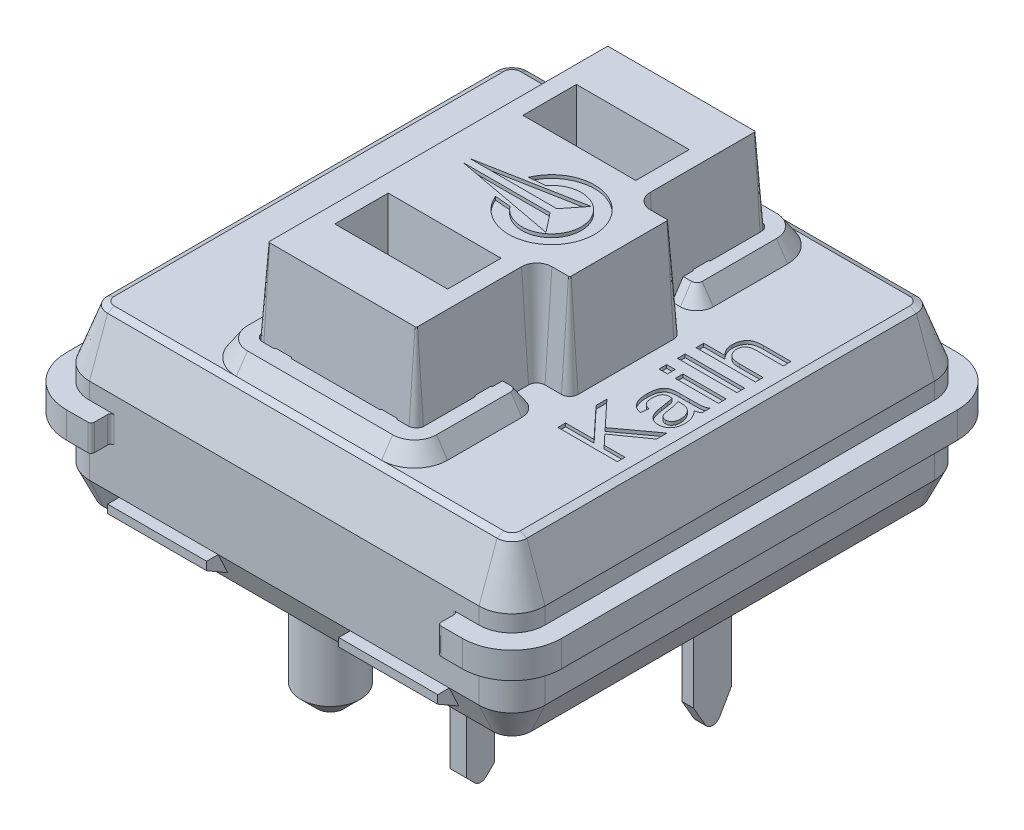
from build123d import *
from OCP.BRepFilletAPI import BRepFilletAPI_MakeChamfer

# Parameters (mm, degrees)
BOSS_EXTRUDE4_DEPTH  = 0.4
BOSS_EXTRUDE5_DEPTH  = 0.5
BOSS_EXTRUDE6_DEPTH  = 1.6
BOSS_EXTRUDE6_TAPER  = 20.000000000000043
CHAMFER1_SIZE        = 0.1
CHAMFER1_SIZE2       = 0.16731571851014881
BOSS_EXTRUDE7_DEPTH  = 0.5
BOSS_EXTRUDE7_TAPER  = 34.000000000000064
CUT_EXTRUDE1_DEPTH   = 11.995908329919814
BOSS_EXTRUDE8_DEPTH  = 0.5
BOSS_EXTRUDE9_DEPTH  = 3
BOSS_EXTRUDE9_DRAFT  = 4.000000000000004
SKETCH13_W           = 1.799999999999999
SKETCH13_H           = 0.23376623376623384
SKETCH13_W_2         = 1.3090909090909086
SKETCH13_H_2         = 0.23376623376623368
SKETCH13_W_3         = 0.25714285714285623
CUT_EXTRUDE2_DEPTH   = 0.1
CUT_EXTRUDE3_DEPTH   = 0.1
BOSS_EXTRUDE10_START = 1.3
BOSS_EXTRUDE10_DEPTH = 1.3
BOSS_EXTRUDE11_DEPTH = 0.9000000000000002
BOSS_EXTRUDE11_TAPER = 25.000000000000018
CUT_EXTRUDE4_DEPTH   = 4
SKETCH19_R           = 1.6
SKETCH19_R_2         = 0.8999999999999999
BOSS_EXTRUDE12_DEPTH = 2.65
CHAMFER2_SIZE        = 0.5
SKETCH20_W           = 0.34999999999999964
SKETCH20_H           = 1.15
SKETCH20_W_2         = 0.5
SKETCH20_H_2         = 0.8499999999999996
BOSS_EXTRUDE13_DEPTH = 3
CUT_EXTRUDE5_REACH   = 18.489
BOSS_EXTRUDE14_START = 2
BOSS_EXTRUDE14_DEPTH = 3
MIRROR2_START        = 2
MIRROR2_COPY_1_DEPTH = 3
CUT_EXTRUDE6_REACH   = 14.137
SKETCH23_W           = 10.5
SKETCH23_H           = 0.599999999999997
FILLET1_R            = 0.1


with BuildPart() as part:
    # Sketch5 → Boss-Extrude4 (new, symmetric)
    with BuildSketch(Plane(origin=(0, 0, 0), x_dir=(1, 0, 0), z_dir=(0, 1, 0))):
        with BuildLine():
            Line((5.999999999999988, -7.4999999999999964), (-5.999999999999988, -7.4999999999999964))
            ThreePointArc((-5.999999999999988, -7.4999999999999964), (-7.06066017177982, -7.060660171779818), (-7.499999999999999, -5.999999999999986))
            Line((-7.499999999999999, -5.999999999999986), (-7.499999999999999, 5.999999999999986))
            ThreePointArc((-7.499999999999999, 5.999999999999986), (-7.06066017177982, 7.060660171779818), (-5.999999999999988, 7.4999999999999964))
            Line((-5.999999999999988, 7.4999999999999964), (5.999999999999988, 7.4999999999999964))
            ThreePointArc((5.999999999999988, 7.4999999999999964), (7.06066017177982, 7.060660171779817), (7.499999999999999, 5.999999999999986))
            Line((7.499999999999999, 5.999999999999986), (7.499999999999999, -5.999999999999986))
            ThreePointArc((7.499999999999999, -5.999999999999986), (7.06066017177982, -7.060660171779817), (5.999999999999988, -7.4999999999999964))
        make_face()
    extrude(amount=BOSS_EXTRUDE4_DEPTH, both=True)

    # Sketch6 → Boss-Extrude5 (add)
    with BuildSketch(Plane(origin=(0, 0.4, 0), x_dir=(1, 0, 0), z_dir=(0, 1, 0))):
        with BuildLine():
            Line((5.899999999999993, -6.900000000000001), (-5.899999999999995, -6.900000000000001))
            ThreePointArc((-5.899999999999995, -6.900000000000001), (-6.607106781186548, -6.607106781186549), (-6.900000000000001, -5.899999999999995))
            Line((-6.900000000000001, -5.899999999999995), (-6.900000000000001, 5.899999999999992))
            ThreePointArc((-6.900000000000001, 5.899999999999992), (-6.607106781186548, 6.6071067811865465), (-5.899999999999995, 6.899999999999999))
            Line((-5.899999999999995, 6.899999999999999), (5.899999999999992, 6.899999999999999))
            ThreePointArc((5.899999999999992, 6.899999999999999), (6.6071067811865465, 6.6071067811865465), (6.899999999999999, 5.899999999999992))
            Line((6.899999999999999, 5.899999999999992), (6.8999999999999995, -5.899999999999995))
            ThreePointArc((6.8999999999999995, -5.899999999999995), (6.607106781186547, -6.607106781186548), (5.899999999999993, -6.900000000000001))
        make_face()
    extrude(amount=BOSS_EXTRUDE5_DEPTH)

    # Sketch7 → Boss-Extrude6 (add)
    with BuildSketch(Plane(origin=(0, 0.9, 0), x_dir=(1, 0, 0), z_dir=(0, 1, 0))):
        with BuildLine():
            Line((-6.900000000000001, 5.899999999999992), (-6.900000000000001, -5.899999999999995))
            ThreePointArc((-6.900000000000001, -5.899999999999995), (-6.607106781186549, -6.607106781186548), (-5.899999999999995, -6.900000000000001))
            Line((-5.899999999999995, -6.900000000000001), (5.899999999999993, -6.900000000000001))
            ThreePointArc((5.899999999999993, -6.900000000000001), (6.607106781186547, -6.607106781186548), (6.8999999999999995, -5.899999999999995))
            Line((6.8999999999999995, -5.899999999999995), (6.899999999999999, 5.899999999999992))
            ThreePointArc((6.899999999999999, 5.899999999999992), (6.6071067811865465, 6.6071067811865465), (5.899999999999992, 6.899999999999999))
            Line((5.899999999999992, 6.899999999999999), (-5.899999999999995, 6.899999999999999))
            ThreePointArc((-5.899999999999995, 6.899999999999999), (-6.607106781186548, 6.6071067811865465), (-6.900000000000001, 5.899999999999992))
        make_face()
    extrude(amount=BOSS_EXTRUDE6_DEPTH, taper=BOSS_EXTRUDE6_TAPER)

    # Chamfer1: one chamfer whose edges measure the first distance from different faces: ONE call of the kernel's chamfer builder (chamfer() names one face for all edges)
    chamfer1_edges_1 = [part.edges().sort_by_distance(p)[0] for p in [
        (-6.195321467907047, 2.5, -6.1953214679070445),
    ]]
    chamfer1_side_1 = [part.faces().sort_by_distance(p)[0] for p in [
        (-6.401214124546798, 1.7000000000000002, -6.4012141245467955),
    ]]
    chamfer1_edges_2 = [part.edges().sort_by_distance(p)[0] for p in [
        (-6.317647625174076, 2.5, 1.38e-15),
    ]]
    chamfer1_side_2 = [part.faces().sort_by_distance(p)[0] for p in [
        (-6.608823812587039, 1.7, 1.04e-15),
    ]]
    chamfer1_edges_3 = [part.edges().sort_by_distance(p)[0] for p in [
        (-6.195321467907047, 2.5, 6.195321467907046),
    ]]
    chamfer1_side_3 = [part.faces().sort_by_distance(p)[0] for p in [
        (-6.401214124546797, 1.7000000000000002, 6.401214124546797),
    ]]
    chamfer1_edges_4 = [part.edges().sort_by_distance(p)[0] for p in [
        (-1.3e-15, 2.5, 6.317647625174076),
    ]]
    chamfer1_side_4 = [part.faces().sort_by_distance(p)[0] for p in [
        (-8.5e-16, 1.7, 6.608823812587039),
    ]]
    chamfer1_edges_5 = [part.edges().sort_by_distance(p)[0] for p in [
        (6.1953214679070445, 2.5, 6.195321467907047),
    ]]
    chamfer1_side_5 = [part.faces().sort_by_distance(p)[0] for p in [
        (6.4012141245467955, 1.7000000000000002, 6.401214124546797),
    ]]
    chamfer1_edges_6 = [part.edges().sort_by_distance(p)[0] for p in [
        (6.317647625174073, 2.5, -3.9e-16),
    ]]
    chamfer1_side_6 = [part.faces().sort_by_distance(p)[0] for p in [
        (6.608823812587037, 1.7000000000000002, 7e-16),
    ]]
    chamfer1_edges_7 = [part.edges().sort_by_distance(p)[0] for p in [
        (6.195321467907045, 2.5, -6.1953214679070445),
    ]]
    chamfer1_side_7 = [part.faces().sort_by_distance(p)[0] for p in [
        (6.4012141245467955, 1.7000000000000002, -6.4012141245467955),
    ]]
    chamfer1_edges_8 = [part.edges().sort_by_distance(p)[0] for p in [
        (-4.1e-16, 2.5, -6.317647625174073),
    ]]
    chamfer1_side_8 = [part.faces().sort_by_distance(p)[0] for p in [
        (-8.5e-16, 1.7, -6.608823812587036),
    ]]
    chamfer1 = BRepFilletAPI_MakeChamfer(part.part.solid().wrapped)
    for e in chamfer1_edges_1:
        chamfer1.Add(CHAMFER1_SIZE, CHAMFER1_SIZE2, e.wrapped, chamfer1_side_1[0].wrapped)  # the first distance lies on this face
    for e in chamfer1_edges_2:
        chamfer1.Add(CHAMFER1_SIZE, CHAMFER1_SIZE2, e.wrapped, chamfer1_side_2[0].wrapped)  # the first distance lies on this face
    for e in chamfer1_edges_3:
        chamfer1.Add(CHAMFER1_SIZE, CHAMFER1_SIZE2, e.wrapped, chamfer1_side_3[0].wrapped)  # the first distance lies on this face
    for e in chamfer1_edges_4:
        chamfer1.Add(CHAMFER1_SIZE, CHAMFER1_SIZE2, e.wrapped, chamfer1_side_4[0].wrapped)  # the first distance lies on this face
    for e in chamfer1_edges_5:
        chamfer1.Add(CHAMFER1_SIZE, CHAMFER1_SIZE2, e.wrapped, chamfer1_side_5[0].wrapped)  # the first distance lies on this face
    for e in chamfer1_edges_6:
        chamfer1.Add(CHAMFER1_SIZE, CHAMFER1_SIZE2, e.wrapped, chamfer1_side_6[0].wrapped)  # the first distance lies on this face
    for e in chamfer1_edges_7:
        chamfer1.Add(CHAMFER1_SIZE, CHAMFER1_SIZE2, e.wrapped, chamfer1_side_7[0].wrapped)  # the first distance lies on this face
    for e in chamfer1_edges_8:
        chamfer1.Add(CHAMFER1_SIZE, CHAMFER1_SIZE2, e.wrapped, chamfer1_side_8[0].wrapped)  # the first distance lies on this face
    add(Compound.cast(chamfer1.Shape()), mode=Mode.REPLACE)

    # Sketch8 → Boss-Extrude7 (add)
    with BuildSketch(Plane(origin=(0, 2.5, 0), x_dir=(1, 0, 0), z_dir=(0, 1, 0))):
        with BuildLine():
            ThreePointArc((2.1999999999999926, -6.150331906663926), (2.907106781186547, -5.857438687850474), (3.1999999999999997, -5.150331906663919))
            Line((3.1999999999999997, -5.150331906663919), (3.1999999999999997, -2.9003319066639257))
            ThreePointArc((3.1999999999999997, -2.9003319066639257), (3.0535533905932737, -2.5467785160706518), (2.6999999999999997, -2.4003319066639257))
            Line((2.6999999999999997, -2.4003319066639257), (2.3000000000000003, -2.4003319066639257))
            Line((2.3000000000000003, -2.4003319066639257), (2.3, 2.4003319066639257))
            Line((2.3, 2.4003319066639257), (2.699999999999996, 2.4003319066639257))
            ThreePointArc((2.699999999999996, 2.4003319066639257), (3.0535533905932737, 2.5467785160706518), (3.1999999999999997, 2.9003319066639293))
            Line((3.1999999999999997, 2.9003319066639293), (3.1999999999999997, 5.150331906663919))
            ThreePointArc((3.1999999999999997, 5.150331906663919), (2.907106781186547, 5.857438687850474), (2.1999999999999926, 6.150331906663926))
            Line((2.1999999999999926, 6.150331906663926), (-2.1999999999999935, 6.150331906663926))
            ThreePointArc((-2.1999999999999935, 6.150331906663926), (-2.907106781186548, 5.857438687850474), (-3.2000000000000006, 5.150331906663919))
            Line((-3.2000000000000006, 5.150331906663919), (-3.2000000000000006, -5.150331906663919))
            ThreePointArc((-3.2000000000000006, -5.150331906663919), (-2.907106781186548, -5.857438687850474), (-2.1999999999999935, -6.150331906663926))
            Line((-2.1999999999999935, -6.150331906663926), (2.1999999999999926, -6.150331906663926))
        make_face()
    extrude(amount=BOSS_EXTRUDE7_DEPTH, taper=BOSS_EXTRUDE7_TAPER)

    # Sketch9 → Cut-Extrude1 (cut, through all)
    with BuildSketch(Plane(origin=(0, 2.5, 0), x_dir=(1, 0, 0), z_dir=(0, 1, 0))):
        with BuildLine():
            Line((-2.1999999999999997, -5.35), (2.2, -5.35))
            ThreePointArc((2.2, -5.35), (2.376776695296637, -5.276776695296636), (2.4500000000000006, -5.1))
            Line((2.4500000000000006, -5.1), (2.4500000000000006, 5.1))
            ThreePointArc((2.4500000000000006, 5.1), (2.376776695296637, 5.276776695296636), (2.2, 5.35))
            Line((2.2, 5.35), (-2.1999999999999997, 5.35))
            ThreePointArc((-2.1999999999999997, 5.35), (-2.3767766952966367, 5.276776695296636), (-2.4499999999999997, 5.1))
            Line((-2.4499999999999997, 5.1), (-2.4499999999999997, -5.1))
            ThreePointArc((-2.4499999999999997, -5.1), (-2.3767766952966367, -5.276776695296636), (-2.1999999999999997, -5.35))
        make_face()
    extrude(amount=CUT_EXTRUDE1_DEPTH, mode=Mode.SUBTRACT)

    # Sketch11 → Boss-Extrude8 (add)
    with BuildSketch(Plane(origin=(0, 2.5, 0), x_dir=(1, 0, 0), z_dir=(0, 1, 0))):
        with BuildLine():
            Line((-1.8598076211353325, 5.35), (-1.3401923788646686, 5.3500000000000005))
            ThreePointArc((-1.3401923788646686, 5.3500000000000005), (-1.6000000000000003, 5.199999999999999), (-1.8598076211353325, 5.35))
        make_face()
        with BuildLine():
            Line((1.3401923788646686, 5.3500000000000005), (1.8598076211353325, 5.35))
            ThreePointArc((1.8598076211353325, 5.35), (1.6000000000000003, 5.199999999999999), (1.3401923788646686, 5.3500000000000005))
        make_face()
        with BuildLine():
            Line((2.4500000000000006, 3.5598076211353322), (2.4500000000000006, 3.040192378864668))
            ThreePointArc((2.4500000000000006, 3.040192378864668), (2.2999999999999994, 3.3), (2.4500000000000006, 3.5598076211353322))
        make_face()
        with BuildLine():
            Line((2.4500000000000006, -3.0401923788646683), (2.4500000000000006, -3.5598076211353313))
            ThreePointArc((2.4500000000000006, -3.5598076211353313), (2.3000000000000007, -3.3), (2.4500000000000006, -3.0401923788646683))
        make_face()
        with BuildLine():
            Line((1.859807621135331, -5.35), (1.3401923788646677, -5.35))
            ThreePointArc((1.3401923788646677, -5.35), (1.6, -5.199999999999998), (1.859807621135331, -5.35))
        make_face()
        with BuildLine():
            Line((-1.3401923788646677, -5.35), (-1.859807621135331, -5.35))
            ThreePointArc((-1.859807621135331, -5.35), (-1.5999999999999992, -5.199999999999999), (-1.3401923788646677, -5.35))
        make_face()
        with BuildLine():
            Line((-2.4499999999999997, -3.5598076211353313), (-2.4499999999999993, -3.0401923788646683))
            ThreePointArc((-2.4499999999999993, -3.0401923788646683), (-2.2999999999999994, -3.3000000000000003), (-2.4499999999999997, -3.5598076211353313))
        make_face()
        with BuildLine():
            Line((-2.449999999999999, 3.0401923788646683), (-2.449999999999999, 3.5598076211353313))
            ThreePointArc((-2.449999999999999, 3.5598076211353313), (-2.299999999999999, 3.3), (-2.449999999999999, 3.0401923788646683))
        make_face()
    extrude(amount=BOSS_EXTRUDE8_DEPTH)


with BuildPart() as boss_extrude9_tool:
    # Sketch12 → Boss-Extrude9 (with draft: the straight prism first)
    with BuildSketch(Plane(origin=(0, 2.5, 0), x_dir=(1, 0, 0), z_dir=(0, 1, 0))):
        with BuildLine():
            ThreePointArc((2.6999999999999993, 1.6999999999999997), (2.5232233047033628, 1.7732233047033628), (2.4499999999999993, 1.9499999999999995))
            Line((2.4499999999999993, 1.9499999999999995), (2.4499999999999997, 5.099999999999998))
            ThreePointArc((2.4499999999999997, 5.099999999999998), (2.3767766952966367, 5.276776695296637), (2.199999999999998, 5.35))
            Line((2.199999999999998, 5.35), (-2.199999999999998, 5.35))
            ThreePointArc((-2.199999999999998, 5.35), (-2.3767766952966367, 5.276776695296637), (-2.4499999999999997, 5.099999999999998))
            Line((-2.4499999999999997, 5.099999999999998), (-2.4499999999999997, -5.099999999999998))
            ThreePointArc((-2.4499999999999997, -5.099999999999998), (-2.3767766952966367, -5.276776695296637), (-2.199999999999998, -5.35))
            Line((-2.199999999999998, -5.35), (2.199999999999998, -5.35))
            ThreePointArc((2.199999999999998, -5.35), (2.3767766952966367, -5.276776695296636), (2.4499999999999997, -5.099999999999998))
            Line((2.4499999999999997, -5.099999999999998), (2.449999999999999, -1.9500000000000004))
            ThreePointArc((2.449999999999999, -1.9500000000000004), (2.5232233047033623, -1.7732233047033634), (2.6999999999999993, -1.7000000000000004))
            Line((2.6999999999999993, -1.7000000000000004), (3.1999999999999975, -1.7000000000000006))
            ThreePointArc((3.1999999999999975, -1.7000000000000006), (3.3767766952966363, -1.6267766952966372), (3.4499999999999993, -1.4499999999999986))
            Line((3.4499999999999993, -1.4499999999999986), (3.4499999999999993, 1.449999999999998))
            ThreePointArc((3.4499999999999993, 1.449999999999998), (3.3767766952966363, 1.6267766952966367), (3.1999999999999975, 1.6999999999999997))
            Line((3.1999999999999975, 1.6999999999999997), (2.6999999999999993, 1.6999999999999997))
        make_face()
        Polygon((-1.5000000000000004, -2.2500000000000013), (1.4999999999999996, -2.2500000000000013), (1.5, -3.4500000000000006), (-1.5, -3.4500000000000006), align=None, mode=Mode.SUBTRACT)
        Polygon((1.4999999999999996, 2.2500000000000013), (1.5, 3.4500000000000006), (-1.5, 3.4500000000000006), (-1.5000000000000004, 2.2500000000000013), align=None, mode=Mode.SUBTRACT)
    extrude(amount=BOSS_EXTRUDE9_DEPTH)
    # Boss-Extrude9: the draft: its side faces are tilted about the plane it starts from
    boss_extrude9_sides = [boss_extrude9_tool.faces().sort_by_distance(p)[0] for p in [
        (2.95, 4, -1.7),
        (2.523223305, 4, -1.773223305),
        (2.45, 4, -3.525),
        (2.376776695, 4, -5.276776695),
        (0, 4, -5.35),
        (-2.376776695, 4, -5.276776695),
        (-2.45, 4, 0),
        (-2.376776695, 4, 5.276776695),
        (0, 4, 5.35),
        (2.376776695, 4, 5.276776695),
        (2.45, 4, 3.525),
        (2.523223305, 4, 1.773223305),
        (2.95, 4, 1.7),
        (3.376776695, 4, 1.626776695),
        (3.45, 4, 0),
        (3.376776695, 4, -1.626776695),
        (0, 4, 2.25),
        (1.5, 4, 2.85),
        (0, 4, 3.45),
        (-1.5, 4, 2.85),
        (0, 4, -2.25),
        (-1.5, 4, -2.85),
        (0, 4, -3.45),
        (1.5, 4, -2.85),
    ]]
    draft(boss_extrude9_sides, Plane(origin=(0, 2.5, 0), x_dir=(1, 0, 0), z_dir=(0, 1, 0)), BOSS_EXTRUDE9_DRAFT)


with BuildPart() as part_1:
    add(part.part)

    # Boss-Extrude9: add boss_extrude9_tool
    add(boss_extrude9_tool.part)

    # Sketch13 → Cut-Extrude2 (cut)
    # profile 1 of 6: a face of its own
    with BuildSketch(Plane(origin=(0, 2.5, 0), x_dir=(1, 0, 0), z_dir=(0, 1, 0))):
        with BuildLine():
            Line((5.808966831260708, 2.641558441558442), (5.808966831260708, 2.407792207792208))
            Line((5.808966831260708, 2.407792207792208), (4.983845078013955, 2.407792207792208))
            add(Edge.make_bspline(
                [(4.983845078013955, 2.407792207792208), (4.970936937987347, 2.407542406260028), (4.945817291259644, 2.4070562846168273), (4.909388829537622, 2.404446327773024), (4.875533983787305, 2.3986845529071656), (4.844041788617271, 2.3916782041743367), (4.815157057405047, 2.3820295974230006), (4.788467982544043, 2.370938235014907), (4.76477812513214, 2.356842463642668), (4.74322837391324, 2.3411870649661166), (4.724636948675216, 2.322986558780508), (4.707844497346048, 2.3033641068930986), (4.694403121572682, 2.2809814749147597), (4.682944049961972, 2.256818630216123), (4.6742465252240155, 2.230417316179967), (4.668184159240792, 2.2019983442445166), (4.66389616835546, 2.1717202021884994), (4.6636423768311674, 2.150786980540251), (4.6635122858061635, 2.1400568181818187)],
                knots=[0, 0, 0, 0, 1.2972783551700766, 2.5245445061948706, 3.6648949627077094, 4.745058113257756, 5.762506365238955, 6.7214970436470525, 7.642596806820658, 8.525874585350033, 9.39109206720355, 10.251017649372987, 11.113376332231878, 12.005421350727158, 12.933884526935351, 13.898554589722258, 14.922819868887679, 16, 16, 16, 16], degree=3))
            add(Edge.make_bspline(
                [(4.6635122858061635, 2.1400568181818187), (4.663785205943969, 2.1292047975292503), (4.664327167446585, 2.107654986414011), (4.66891947185136, 2.0757509701628627), (4.6760240121807595, 2.0445829921752665), (4.686851369518582, 2.014620956025939), (4.700167829324783, 1.9854327210485339), (4.716078390118673, 1.9568415750558832), (4.73570868933388, 1.9296426160727786), (4.7575320886071655, 1.9029132005118794), (4.783330672401592, 1.8782273309201394), (4.814429220574406, 1.8572274976130505), (4.849948580547092, 1.8394512413448831), (4.89005592438308, 1.8249217409321132), (4.934595652434697, 1.8136176473029308), (4.983754863262196, 1.8059125229971111), (5.037541460961735, 1.800531571486795), (5.075023484650014, 1.800181881897381), (5.094518779312656, 1.8000000000000005)],
                knots=[0, 0, 0, 0, 0.8362054097120233, 1.6605265700973175, 2.4801317730402395, 3.2965059310675793, 4.1113678837462215, 4.951934169313966, 5.813922886019306, 6.693615501295894, 7.6099018852787, 8.554965245663075, 9.57498769822485, 10.664785272825679, 11.83718286940016, 13.111757415166943, 14.497756131931636, 16, 16, 16, 16], degree=3))
            Line((5.094518779312656, 1.8000000000000005), (5.808966831260708, 1.8000000000000005))
            Line((5.808966831260708, 1.8000000000000005), (5.808966831260708, 1.5662337662337664))
            Line((5.808966831260708, 1.5662337662337664), (4.008966831260709, 1.5662337662337664))
            Line((4.008966831260709, 1.5662337662337664), (4.008966831260709, 1.8000000000000005))
            Line((4.008966831260709, 1.8000000000000005), (4.654746052039929, 1.8000000000000005))
            add(Edge.make_bspline(
                [(4.654746052039929, 1.8000000000000005), (4.640587268225019, 1.8132416381214425), (4.612790149898402, 1.8392381775496645), (4.576436737364106, 1.8823687896270296), (4.545512997028346, 1.9278700105851003), (4.520153010498332, 1.9758505241977433), (4.500661093710448, 2.026392369279579), (4.486816633622833, 2.079314401328632), (4.478177777445173, 2.1347826772544454), (4.477065304085907, 2.1726549891213955), (4.476499298793176, 2.1919237012987014)],
                knots=[0, 0, 0, 0, 1.0459544956214468, 2.0534617421327868, 3.0380182977429215, 4.011318372678219, 4.9769517403428445, 5.955962446214011, 6.9600325577727205, 8, 8, 8, 8], degree=3))
            add(Edge.make_bspline(
                [(4.476499298793176, 2.1919237012987014), (4.477151582793741, 2.21277888482019), (4.478447675797427, 2.254218284574451), (4.488265102185742, 2.3157097148811725), (4.504316498091638, 2.3757223907282032), (4.523072482923445, 2.424142919941128), (4.5413475287910305, 2.460944025525365), (4.556678390313753, 2.486720067646266), (4.573903343982798, 2.510222970711106), (4.592950461451007, 2.5314273616548295), (4.613634983780957, 2.550582276277968), (4.635796332997107, 2.567919296762635), (4.660269486175782, 2.582453577853053), (4.686358421444562, 2.595400662956551), (4.714781427402648, 2.6063064439066825), (4.745540233069591, 2.6157833065900173), (4.778855645113474, 2.623760719216385), (4.814825745795724, 2.630327347062428), (4.853357065642652, 2.6353283002399457), (4.894542377636706, 2.6389704691017455), (4.938285293293962, 2.641164747420887), (4.968379824838619, 2.64142480221953), (4.983845078013955, 2.641558441558442)],
                knots=[0, 0, 0, 0, 1.5968089331520274, 3.172870842583649, 4.756281426330583, 6.34771723513016, 7.140081275106954, 7.901324872717275, 8.641779931057476, 9.368185131844692, 10.08081263976222, 10.798910289841917, 11.5185804625579, 12.256741901371203, 13.027352034049343, 13.847329809568349, 14.720365742585669, 15.649518335311587, 16.64656909042814, 17.695141442598235, 18.815558199646286, 20, 20, 20, 20], degree=3))
            Line((4.983845078013955, 2.641558441558442), (5.808966831260708, 2.641558441558442))
        make_face()
    # profile 2 of 6: a face of its own
    with BuildSketch(Plane(origin=(0, 2.5, 0), x_dir=(1, 0, 0), z_dir=(0, 1, 0))):
        with Locations((4.908966831260709, 1.1220779220779225)):
            Rectangle(SKETCH13_W, SKETCH13_H)
    # profile 3 of 6: a face of its own
    with BuildSketch(Plane(origin=(0, 2.5, 0), x_dir=(1, 0, 0), z_dir=(0, 1, 0))):
        with Locations((5.154421376715254, 0.5610389610389616)):
            Rectangle(SKETCH13_W_2, SKETCH13_H_2)
    # profile 4 of 6: a face of its own
    with BuildSketch(Plane(origin=(0, 2.5, 0), x_dir=(1, 0, 0), z_dir=(0, 1, 0))):
        with Locations((4.137538259832137, 0.5610389610389616)):
            Rectangle(SKETCH13_W_3, SKETCH13_H_2)
    # profile 5 of 6: a face of its own
    with BuildSketch(Plane(origin=(0, 2.5, 0), x_dir=(1, 0, 0), z_dir=(0, 1, 0))):
        with BuildLine():
            Line((5.808966831260708, 0.18701298701298769), (5.808966831260708, -0.04675324675324595))
            add(Edge.make_bspline(
                [(5.808966831260708, -0.04675324675324595), (5.7976142124163745, -0.05478679368631185), (5.7743238351672606, -0.07126795466644732), (5.733813191132734, -0.08980997433740275), (5.689119615174492, -0.10624044539384754), (5.656887568182907, -0.11325507851090857), (5.640216831260709, -0.11688311688311617)],
                knots=[0, 0, 0, 0, 0.903907977573099, 1.8544054094329567, 2.8902770286238817, 4, 4, 4, 4], degree=3))
            add(Edge.make_bspline(
                [(5.640216831260709, -0.11688311688311617), (5.655516269991555, -0.13501758155964783), (5.685611532777377, -0.17068957512239877), (5.724423214156069, -0.22753996575106764), (5.758209315632795, -0.2850162411995688), (5.785193746113217, -0.3439309765148028), (5.806296030921507, -0.40396525614362766), (5.821118572850905, -0.4650232117771859), (5.830806032465317, -0.5272477785338032), (5.83182865628761, -0.5691604908149904), (5.832343454637331, -0.5902597402597396)],
                knots=[0, 0, 0, 0, 1.0892239949737048, 2.142593786481002, 3.1574900276556006, 4.148481358184637, 5.114232063249363, 6.075958248606488, 7.031419475255834, 8, 8, 8, 8], degree=3))
            add(Edge.make_bspline(
                [(5.832343454637331, -0.5902597402597396), (5.832153360297348, -0.6068352336235396), (5.831783364459901, -0.6390974437912494), (5.826299867785243, -0.6860584678131948), (5.818566199820707, -0.7303404833298883), (5.807164390100491, -0.7719074962510519), (5.792565368740574, -0.8108311868327565), (5.774591503740437, -0.8471820687217165), (5.753427790168004, -0.8809496085632283), (5.728914091941531, -0.9115819072067921), (5.701926449075696, -0.9389415065317661), (5.672743481759093, -0.9630412796162902), (5.641437274499284, -0.9835012763922452), (5.607803212122262, -1.0000777379656591), (5.572247331081473, -1.012844349874836), (5.534551659180995, -1.0220298965542784), (5.49476474669227, -1.027559476424988), (5.46746671619991, -1.0282300400753384), (5.453569103987981, -1.028571428571428)],
                knots=[0, 0, 0, 0, 1.2168275773517123, 2.368408962361388, 3.4683010163723482, 4.516243969315997, 5.529495403481963, 6.5174065446954765, 7.490059769080957, 8.451006561644878, 9.39329404916929, 10.30823430893489, 11.226054902901527, 12.133974608059562, 13.056228933753905, 13.995455658021518, 14.979472898814782, 16, 16, 16, 16], degree=3))
            add(Edge.make_bspline(
                [(5.453569103987981, -1.028571428571428), (5.440276716431007, -1.0282386520238744), (5.414063323195936, -1.0275823965195083), (5.375806254773276, -1.021871116649069), (5.3390927196081, -1.0132772402654373), (5.304512495067037, -1.0003745013096057), (5.271566778477137, -0.9841331764233306), (5.240409017381131, -0.9643582816606489), (5.211090288328932, -0.9407738117304028), (5.1833836727754115, -0.9136089664633258), (5.15795231534794, -0.8817760352618369), (5.13488061401357, -0.844866649676713), (5.114139733934651, -0.8025902440879535), (5.095679414069346, -0.754997155547491), (5.079325113390285, -0.7022504346619654), (5.065164097593691, -0.6443006182713761), (5.053127451273279, -0.5811412956759465), (5.047187307794613, -0.5370866020377416), (5.044112935156812, -0.5142857142857136)],
                knots=[0, 0, 0, 0, 0.8723930238073564, 1.7204118741329395, 2.5348632349864415, 3.3443153788029036, 4.138098067301036, 4.94323479147576, 5.762342769512937, 6.604727131961653, 7.486268004825613, 8.431224693875162, 9.457417050898199, 10.573914373813508, 11.780129899965775, 13.081285495030452, 14.489394061968598, 16, 16, 16, 16], degree=3))
            Line((5.044112935156812, -0.5142857142857136), (5.013065857234734, -0.3075487012987006))
            add(Edge.make_bspline(
                [(5.013065857234734, -0.3075487012987006), (5.009896710319499, -0.2890201951662468), (5.003852868143418, -0.2536847027393368), (4.993323302570418, -0.2032936700516332), (4.98157734400181, -0.15810403775962822), (4.971952893840244, -0.13010418045169944), (4.967408389702267, -0.11688311688311617)],
                knots=[0, 0, 0, 0, 1.1488224325496723, 2.190905520122856, 3.145775892462998, 4, 4, 4, 4], degree=3))
            add(Edge.make_bspline(
                [(4.967408389702267, -0.11688311688311617), (4.95304107021996, -0.11694396018433391), (4.926493015823697, -0.11705638695067444), (4.890070365263306, -0.11806677840113408), (4.8604658690387765, -0.11983126638462667), (4.8364582839742125, -0.12214155383125126), (4.81566680551623, -0.12674692451881112), (4.795757381699826, -0.13432927622266846), (4.775374880962566, -0.14450518928822909), (4.754952336348308, -0.15769797821147805), (4.734703780341986, -0.17395791515244927), (4.7174165483276935, -0.1957166318549965), (4.70150768066083, -0.22127282907797702), (4.6875739870774344, -0.2513427888570909), (4.676773198610864, -0.28648013751264984), (4.668775091981783, -0.32672078121836107), (4.664166633552748, -0.3724577255824632), (4.6637381327209235, -0.40481871911371503), (4.6635122858061635, -0.4218749999999993)],
                knots=[0, 0, 0, 0, 1.35198280768947, 2.4982052612913668, 3.427994317730636, 4.142845712581893, 4.765440227987405, 5.4251923990055335, 6.1425184454865365, 6.905253036974828, 7.710596233249315, 8.573154591471647, 9.504636226477706, 10.54009170818831, 11.681494222231183, 12.955497740723338, 14.395355641877869, 16, 16, 16, 16], degree=3))
            add(Edge.make_bspline(
                [(4.6635122858061635, -0.4218749999999993), (4.66393136843903, -0.4435889493922598), (4.664727068565052, -0.4848165997715033), (4.674441945468665, -0.5430927387032761), (4.689451627101745, -0.5943968270216485), (4.7074865821939555, -0.63235510297392), (4.726433230928832, -0.6582766817166884), (4.743016668396578, -0.6759110272748095), (4.762183690184085, -0.6920033701799613), (4.783843221089238, -0.7068062978877482), (4.808520052437821, -0.7194073324106408), (4.8356450202931605, -0.7306943483333374), (4.865364001637794, -0.7407541968167183), (4.886391065493827, -0.7455623622273017), (4.897278519572397, -0.7480519480519473)],
                knots=[0, 0, 0, 0, 1.7542902106465328, 3.330820301812233, 4.7604713821246065, 6.0681986003606685, 6.702305717905518, 7.350099905606375, 8.020759658183286, 8.72256691010055, 9.46680753417905, 10.256730987815589, 11.097365117322028, 12, 12, 12, 12], degree=3))
            Line((4.897278519572397, -0.7480519480519473), (4.869518779312656, -0.9818181818181811))
            add(Edge.make_bspline(
                [(4.869518779312656, -0.9818181818181811), (4.853611193018221, -0.9786017816846534), (4.822520424961833, -0.9723154508311147), (4.7779582503051286, -0.9577116763605429), (4.736375461913592, -0.9401017094407711), (4.698028692803322, -0.9184783635958045), (4.662206250314258, -0.8942256914916684), (4.630102405191615, -0.8653595010460773), (4.60073240624794, -0.8334501386405557), (4.574196642027063, -0.7982237274884666), (4.551183080742637, -0.7591558796600055), (4.531227592657335, -0.7166636573486271), (4.513752885558066, -0.6708727288596874), (4.500747320962618, -0.6212823703099524), (4.489461909514712, -0.5685697104505628), (4.48216824521634, -0.5122547146028833), (4.477156426962759, -0.45252638307886056), (4.476722437161997, -0.4115373902981895), (4.476499298793176, -0.39046266233766164)],
                knots=[0, 0, 0, 0, 0.9951774450735463, 1.9450361951236252, 2.8721424933872783, 3.7618547880388564, 4.642675727118209, 5.5212756524060795, 6.404343627695985, 7.300931216189511, 8.222238890582595, 9.181425829138911, 10.179208271910753, 11.225067007971875, 12.32407275364409, 13.485342137314333, 14.707074100271779, 15.999999999999998, 15.999999999999998, 15.999999999999998, 15.999999999999998], degree=3))
            add(Edge.make_bspline(
                [(4.476499298793176, -0.39046266233766164), (4.476690890893722, -0.37146355115084456), (4.477060875118252, -0.3347742962221728), (4.480416422626953, -0.28163635012060095), (4.485659187798085, -0.23246808108091682), (4.493498525945788, -0.18727794431895398), (4.5026469171851735, -0.1457532426678561), (4.514752157830967, -0.10832524552016949), (4.528482033470439, -0.07448630485279219), (4.545116255570697, -0.04485864995814117), (4.563264378078302, -0.01855796061888742), (4.581670847281791, 0.00547334865447952), (4.601749896386381, 0.02621628443629191), (4.621820185599408, 0.04508781077848085), (4.643537404904793, 0.0604805419614025), (4.665690642724296, 0.0738796146888784), (4.689228602685101, 0.08404616835430385), (4.722566345759465, 0.0943999283171139), (4.768238755204122, 0.10365778184610963), (4.828163487433543, 0.1115379776553433), (4.895134857767431, 0.11622508593443337), (4.9420761195692435, 0.11665683743575028), (4.966677870221747, 0.11688311688311769)],
                knots=[0, 0, 0, 0, 1.3680119790864425, 2.6417730678372706, 3.8326947334090917, 4.926724950007907, 5.9433607856030335, 6.891650018276866, 7.756279054183268, 8.5686987674416, 9.332293288262912, 10.056676126852098, 10.745093071296735, 11.409183828571438, 12.03703833990536, 12.658060448387348, 13.270544693548068, 13.877797974739176, 15.169269560119256, 16.620050137650292, 18.228580133133942, 20, 20, 20, 20], degree=3))
            Line((4.966677870221747, 0.11688311688311769), (5.263634039052916, 0.11688311688311769))
            add(Edge.make_bspline(
                [(5.263634039052916, 0.11688311688311769), (5.285306604219437, 0.11680766704013286), (5.326826888673487, 0.11666312028626807), (5.386239281380564, 0.11764517754584121), (5.4401808290261755, 0.1182072909926659), (5.488518290325094, 0.11932409986274001), (5.531263560697876, 0.1206639341543883), (5.5683832596522675, 0.12268531406128662), (5.5999640343828165, 0.1241621792101879), (5.634654478790087, 0.12759156067832103), (5.674206196801377, 0.13402894690695613), (5.720028491512467, 0.14648759100218836), (5.7652765300564655, 0.16413567534602305), (5.7942463337230565, 0.17930497400370782), (5.808966831260708, 0.18701298701298769)],
                knots=[0, 0, 0, 0, 1.4020777770497348, 2.686099577161881, 3.844102432396371, 4.891988820243759, 5.814117699366312, 6.610652945285454, 7.297068948043889, 7.85903618239089, 8.865208258249554, 9.885586107423354, 10.925597672063347, 12, 12, 12, 12], degree=3))
        make_face()
        with BuildLine():
            Line((5.231491181910059, -0.11688311688311617), (5.154421376715254, -0.11688311688311617))
            add(Edge.make_bspline(
                [(5.154421376715254, -0.11688311688311617), (5.163538374613043, -0.14747267198052594), (5.182578995621711, -0.21135818911712592), (5.205221559389253, -0.3133502532226805), (5.226635689822146, -0.4247120728618546), (5.239058906237353, -0.5224414562363454), (5.251092974071679, -0.6000560066001811), (5.265639576753102, -0.6516246800568167), (5.284349500018401, -0.6956652159816192), (5.307786476295021, -0.7319925996799516), (5.3361540028935375, -0.7602818361734104), (5.368992798805446, -0.780499346457833), (5.406475469569275, -0.7926975490106483), (5.432899105806853, -0.7940845112753719), (5.446629168923046, -0.7948051948051941)],
                knots=[0, 0, 0, 0, 1.446121225911983, 3.020187840764769, 4.732247023019203, 6.583196502551875, 7.484893360313893, 8.288294041376107, 9.004862087602321, 9.6460887311044, 10.235252101471714, 10.804947704369333, 11.379035372019407, 12, 12, 12, 12], degree=3))
            add(Edge.make_bspline(
                [(5.446629168923046, -0.7948051948051941), (5.460491689532467, -0.7939842827205499), (5.4876249278722895, -0.7923775039913225), (5.526238858135616, -0.7790305654380151), (5.560657043945748, -0.7571054328140445), (5.590913501868879, -0.727149957006497), (5.61552960733233, -0.6888099645478853), (5.63340786038711, -0.6429337775462531), (5.64334186146863, -0.5895830167494668), (5.644641620612083, -0.5518277417010625), (5.645330467624344, -0.5318181818181812)],
                knots=[0, 0, 0, 0, 0.8977169149362771, 1.7571095258176086, 2.616284247168069, 3.5268401459519625, 4.4975412941161785, 5.550848533269103, 6.701997459349198, 8, 8, 8, 8], degree=3))
            add(Edge.make_bspline(
                [(5.645330467624344, -0.5318181818181812), (5.645059816486738, -0.5182914366917553), (5.644526802104939, -0.4916521631417747), (5.639999444320767, -0.45232488130619447), (5.632693989435125, -0.41422847170043825), (5.622564955468927, -0.377116921177217), (5.608861803026345, -0.3414687079039025), (5.592867724541663, -0.3067108371607533), (5.5732979775351685, -0.2737084251734532), (5.551687240313811, -0.24163249919229488), (5.52610708733106, -0.2122395124236023), (5.49624667626021, -0.18632947228497648), (5.461999306362794, -0.1648604753962989), (5.423805879579481, -0.14718964027836165), (5.381535440461846, -0.13329842918051105), (5.335095634428324, -0.12370284527253757), (5.284610176179945, -0.11772783982109081), (5.249650332373793, -0.11717189213463755), (5.231491181910059, -0.11688311688311617)],
                knots=[0, 0, 0, 0, 0.9742687295202695, 1.9187033506071718, 2.847654724651387, 3.766990184658006, 4.685823367012852, 5.596202204231952, 6.519920943638875, 7.44692391584235, 8.379347399321487, 9.318389875563016, 10.28445050102422, 11.281203512920856, 12.343569689907493, 13.482447171285905, 14.692310501428114, 16, 16, 16, 16], degree=3))
        make_face(mode=Mode.SUBTRACT)
    # profile 6 of 6: a face of its own
    with BuildSketch(Plane(origin=(0, 2.5, 0), x_dir=(1, 0, 0), z_dir=(0, 1, 0))):
        Polygon((5.808966831260708, -1.1162337662337647), (5.808966831260708, -1.4318181818181803), (4.89253014294902, -2.0794237012987), (5.177798000091877, -2.3844155844155828), (5.808966831260708, -2.3844155844155828), (5.808966831260708, -2.618181818181817), (4.008966831260709, -2.618181818181817), (4.008966831260709, -2.3844155844155828), (4.870249298793176, -2.3844155844155828), (4.008966831260709, -1.4628652597402583), (4.008966831260709, -1.1337662337662322), (4.731085337754215, -1.9062905844155829), align=None)
    extrude(amount=-CUT_EXTRUDE2_DEPTH, mode=Mode.SUBTRACT)

    # Sketch14 → Cut-Extrude3 (cut)
    with BuildSketch(Plane(origin=(0, 5.5, 0), x_dir=(1, 0, 0), z_dir=(0, 1, 0))):
        with BuildLine():
            Line((-6e-17, 0.5), (0.48160627441798054, 0.542135089294529))
            ThreePointArc((0.48160627441798054, 0.542135089294529), (2.1, 0), (0.48160627441798065, -0.5421350892945288))
            Line((0.48160627441798065, -0.5421350892945288), (6e-17, -0.5))
            ThreePointArc((6e-17, -0.5), (2.5, 0), (-6e-17, 0.5))
        make_face()
        Polygon((-1.3770266337362267, 0.10429765388477082), (1.2555931951855341, 0.10429765388477082), (1.7122269842043876, 0.6819198827291325), align=None)
        Polygon((1.2555931951855333, -0.10429765388477082), (1.7122269842043867, -0.6819198827291325), (-1.3770266337362258, -0.10429765388477082), align=None)
    extrude(amount=-CUT_EXTRUDE3_DEPTH, mode=Mode.SUBTRACT)

    # Sketch16 → Boss-Extrude10 (add)
    with BuildSketch(Plane.XZ.offset(0.4).offset(BOSS_EXTRUDE10_START)):
        with BuildLine():
            Line((5.900000000000002, -6.900000000000002), (-5.899999999999999, -6.900000000000004))
            ThreePointArc((-5.899999999999999, -6.900000000000004), (-6.6071067811865465, -6.607106781186552), (-6.899999999999999, -5.900000000000004))
            Line((-6.899999999999999, -5.900000000000004), (-6.899999999999999, 5.8999999999999915))
            ThreePointArc((-6.899999999999999, 5.8999999999999915), (-6.6071067811865465, 6.607106781186545), (-5.899999999999992, 6.899999999999999))
            Line((-5.899999999999992, 6.899999999999999), (5.900000000000002, 6.8999999999999995))
            ThreePointArc((5.900000000000002, 6.8999999999999995), (6.60710678118655, 6.6071067811865465), (6.900000000000002, 5.8999999999999995))
            Line((6.900000000000002, 5.8999999999999995), (6.900000000000002, -5.900000000000002))
            ThreePointArc((6.900000000000002, -5.900000000000002), (6.60710678118655, -6.60710678118655), (5.900000000000002, -6.900000000000002))
        make_face()
    extrude(amount=-BOSS_EXTRUDE10_DEPTH)

    # Sketch17 → Boss-Extrude11 (add)
    with BuildSketch(Plane.XZ.offset(1.7)):
        with BuildLine():
            Line((-5.899999999999999, -6.900000000000004), (5.900000000000002, -6.900000000000002))
            ThreePointArc((5.900000000000002, -6.900000000000002), (6.60710678118655, -6.60710678118655), (6.900000000000002, -5.900000000000002))
            Line((6.900000000000002, -5.900000000000002), (6.900000000000002, 5.8999999999999995))
            ThreePointArc((6.900000000000002, 5.8999999999999995), (6.60710678118655, 6.6071067811865465), (5.900000000000002, 6.8999999999999995))
            Line((5.900000000000002, 6.8999999999999995), (-5.899999999999992, 6.899999999999999))
            ThreePointArc((-5.899999999999992, 6.899999999999999), (-6.6071067811865465, 6.607106781186546), (-6.899999999999999, 5.8999999999999915))
            Line((-6.899999999999999, 5.8999999999999915), (-6.899999999999999, -5.900000000000004))
            ThreePointArc((-6.899999999999999, -5.900000000000004), (-6.6071067811865465, -6.607106781186552), (-5.899999999999999, -6.900000000000004))
        make_face()
    extrude(amount=BOSS_EXTRUDE11_DEPTH, taper=BOSS_EXTRUDE11_TAPER)

    # Sketch18 → Cut-Extrude4 (cut)
    with BuildSketch(Plane.XZ.offset(2.6)):
        Polygon((-6.275, 2.5000000000000013), (-3.125, 2.5000000000000013), (-3.1249999999999996, -2.4999999999999987), (-6.2749999999999995, -2.4999999999999987), align=None)
    extrude(amount=-CUT_EXTRUDE4_DEPTH, mode=Mode.SUBTRACT)

    # Sketch19 → Boss-Extrude12 (add)
    with BuildSketch(Plane.XZ.offset(2.6)):
        with Locations(Location((0, 0, 0), (0, 0, 270))):
            Circle(SKETCH19_R)
        with Locations(Location((0, 5.5, 0), (0, 0, 270))):
            Circle(SKETCH19_R_2)
        with Locations(Location((0, -5.5, 0), (0, 0, 90))):
            Circle(SKETCH19_R_2)
    extrude(amount=BOSS_EXTRUDE12_DEPTH)

    # Chamfer2
    chamfer2_edges = [part_1.edges().sort_by_distance(p)[0] for p in [
        (4.9e-16, -5.25, 1.6),
        (2.8e-16, -5.25, 6.4),
        (-1.7e-16, -5.25, -6.4),
    ]]
    chamfer(chamfer2_edges, length=CHAMFER2_SIZE)

    # Sketch20 → Boss-Extrude13 (add)
    with BuildSketch(Plane.XZ.offset(2.6)):
        with Locations((5.9, 0)):
            Rectangle(SKETCH20_W, SKETCH20_H)
        with Locations((3.8, 5)):
            Rectangle(SKETCH20_W_2, SKETCH20_H_2)
    extrude(amount=BOSS_EXTRUDE13_DEPTH)

    # Cut-Extrude5: up to this face of the body (flat: up to its plane)
    cut_extrude5_end = Plane(part_1.part.faces().sort_by_distance((3.55, -4.1, 5))[0])
    # Sketch21 → Cut-Extrude5 (cut, up to the picked face)
    with BuildSketch(Plane(origin=(6.075, 0, 0), x_dir=(0, 0, -1), z_dir=(1, 0, 0)), mode=Mode.PRIVATE) as cut_extrude5_sk1:
        with BuildLine():
            Line((-0.575, -4.854070785647887), (-0.21650635094611032, -5.474999999999998))
            ThreePointArc((-0.21650635094611032, -5.474999999999998), (-1e-16, -5.6), (0.21650635094610995, -5.474999999999998))
            Line((0.21650635094610995, -5.474999999999998), (0.575, -4.854070785647887))
            Line((0.575, -4.854070785647887), (0.575, -6.700000000000001))
            Line((0.575, -6.700000000000001), (-5.425, -6.700000000000001))
            Line((-5.425, -6.700000000000001), (-5.425, -5.278553390593273))
            Line((-5.425, -5.278553390593273), (-5.17677669529664, -5.526776695296638))
            ThreePointArc((-5.17677669529664, -5.526776695296638), (-5.000000000000001, -5.600000000000002), (-4.823223304703363, -5.526776695296636))
            Line((-4.823223304703363, -5.526776695296636), (-4.575, -5.278553390593272))
            Line((-4.575, -5.278553390593272), (-4.575, -5.7))
            Line((-4.575, -5.7), (-0.5749999999999998, -5.7))
            Line((-0.5749999999999998, -5.7), (-0.575, -4.854070785647887))
        make_face()
    cut_extrude5_tool1 = split(extrude(cut_extrude5_sk1.sketch, amount=-CUT_EXTRUDE5_REACH, mode=Mode.PRIVATE), bisect_by=cut_extrude5_end, keep=Keep.BOTH, mode=Mode.PRIVATE)
    add(cut_extrude5_tool1.solids().sort_by(Axis((6.075, -6.130426, 2.337222), (-1, 0, 0)))[0], mode=Mode.SUBTRACT)

    # Sketch22 → Boss-Extrude14 (add)
    with BuildSketch(Plane(origin=(0, 0, 0), x_dir=(0, 0, -1), z_dir=(1, 0, 0)).offset(BOSS_EXTRUDE14_START)):
        Polygon((-6.8999999999999995, -1.7), (-7.25, -1.7), (-7.25, -1.95), (-6.611533244723425, -2.3186189530275523), align=None)
    boss_extrude14 = extrude(amount=BOSS_EXTRUDE14_DEPTH)

    # Mirror1: Boss-Extrude14 across plane
    add(boss_extrude14.mirror(Plane(origin=(0, 0, 0), x_dir=(0, 0, 1), z_dir=(1, 0, 0))))

    # Mirror2: Boss-Extrude14 across plane
    add(boss_extrude14.mirror(Plane.XY))

    # Mirror2 copy 1 sketch → Mirror2 copy 1 (add)
    with BuildSketch(Plane.ZY.offset(MIRROR2_START)):
        Polygon((-6.8999999999999995, -1.7), (-7.25, -1.7), (-7.25, -1.95), (-6.611533244723425, -2.3186189530275523), align=None)
    extrude(amount=MIRROR2_COPY_1_DEPTH)

    # Sketch23 → Cut-Extrude6 (cut, up to next)
    with BuildSketch(Plane.XZ.offset(0.4), mode=Mode.PRIVATE) as cut_extrude6_sk1:
        with Locations((0, 7.1999999999999975)):
            Rectangle(SKETCH23_W, SKETCH23_H)
    cut_extrude6_tool1 = extrude(cut_extrude6_sk1.sketch, amount=-CUT_EXTRUDE6_REACH, mode=Mode.PRIVATE) & part_1.part
    # Sketch23 → Cut-Extrude6 (cut, up to next)
    with BuildSketch(Plane.XZ.offset(0.4), mode=Mode.PRIVATE) as cut_extrude6_sk2:
        with Locations((0, -7.1999999999999975)):
            Rectangle(SKETCH23_W, SKETCH23_H)
    cut_extrude6_tool2 = extrude(cut_extrude6_sk2.sketch, amount=-CUT_EXTRUDE6_REACH, mode=Mode.PRIVATE) & part_1.part
    add(cut_extrude6_tool1.solids().sort_by_distance((0, -0.4, 7.2))[0], mode=Mode.SUBTRACT)
    add(cut_extrude6_tool2.solids().sort_by_distance((0, -0.4, -7.2))[0], mode=Mode.SUBTRACT)

    # Fillet1
    fillet1_edges = [part_1.edges().sort_by_distance(p)[0] for p in [
        (-5.25, 0, 6.8999999999999995),
        (-5.25, 0, 7.4999999999999964),
        (5.25, 0, 7.4999999999999964),
        (5.25, 0, 6.8999999999999995),
        (5.25, 0, -7.4999999999999964),
        (-5.25, 0, -7.4999999999999964),
        (-5.25, 0, -6.8999999999999995),
        (5.25, 0, -6.8999999999999995),
    ]]
    fillet(fillet1_edges, radius=FILLET1_R)


solid = part_1.part
